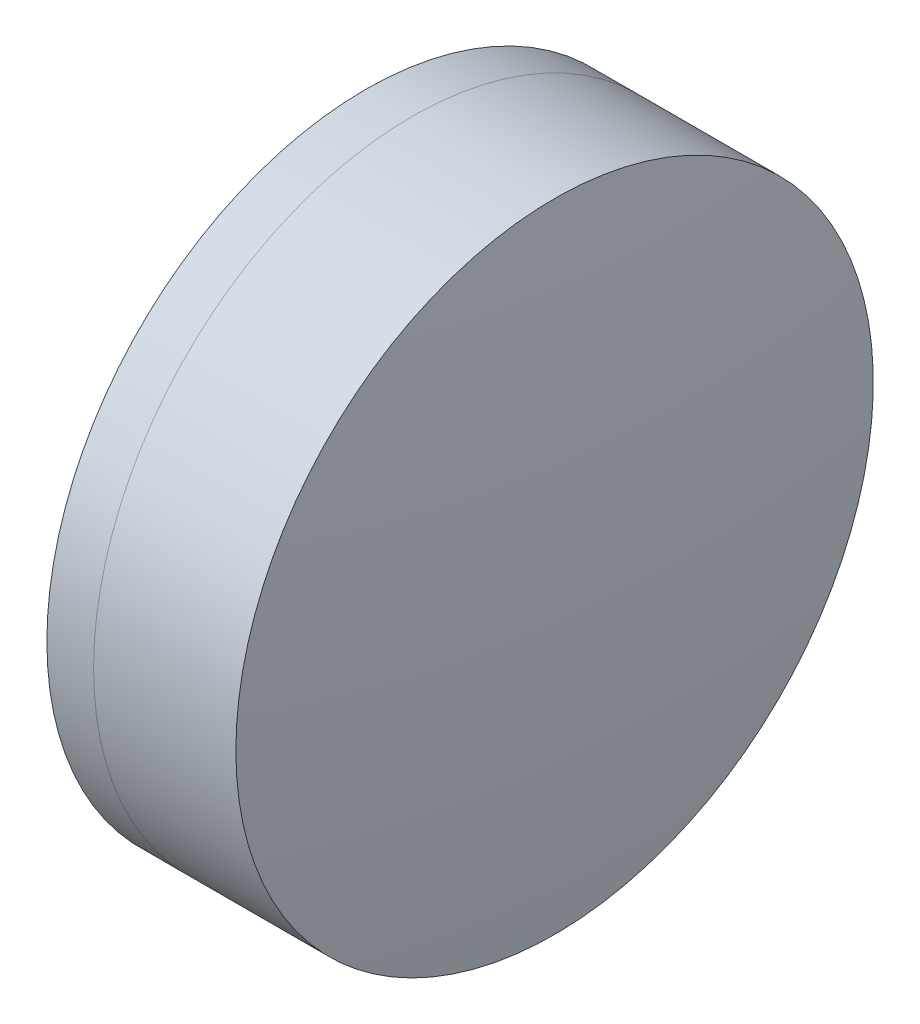
from build123d import *


with BuildPart() as part:
    # 草图1 one side → 旋转1 (revolve)
    with BuildSketch(Plane(origin=(0, 0, 0), x_dir=(1, 0, 0), z_dir=(0, 1, 0)), mode=Mode.PRIVATE) as revolve_1_sk:
        with BuildLine():
            ThreePointArc((276.236342992, 12.7), (273.526245834, 6.605307749), (272.598986555, 0))
            Line((272.598986555, 0), (283.098986555, 0))
            ThreePointArc((283.098986555, 0), (281.803063337, 6.825010157), (278.095682189, 12.7))
            Line((278.095682189, 12.7), (276.236342992, 12.7))
        make_face()
    revolve(revolve_1_sk.sketch.rotate(Axis((124.523309526, 0, 0), (1, 0, 0)), 180), axis=Axis((124.523309526, 0, 0), (1, 0, 0)))  # turned: the seam where the file's is


with BuildPart() as body_2:
    # 草图2 one side → 旋转3 (revolve)
    with BuildSketch(Plane(origin=(0, 0, 0), x_dir=(1, 0, 0), z_dir=(0, 1, 0)), mode=Mode.PRIVATE) as revolve_3_sk:
        with BuildLine():
            Line((283.766338758, 12.7), (278.095682189, 12.7))
            ThreePointArc((278.095682189, 12.7), (281.803063337, 6.825010157), (283.098986555, 0))
            Line((283.098986555, 0), (284.598986555, 0))
            ThreePointArc((284.598986555, 0), (284.39060139, 6.363633049), (283.766338758, 12.7))
        make_face()
    revolve(revolve_3_sk.sketch.rotate(Axis((-0.551919993, 0, 0), (1, 0, 0)), 180), axis=Axis((-0.551919993, 0, 0), (1, 0, 0)))  # turned: the seam where the file's is


solid = Compound([part.part, body_2.part])
